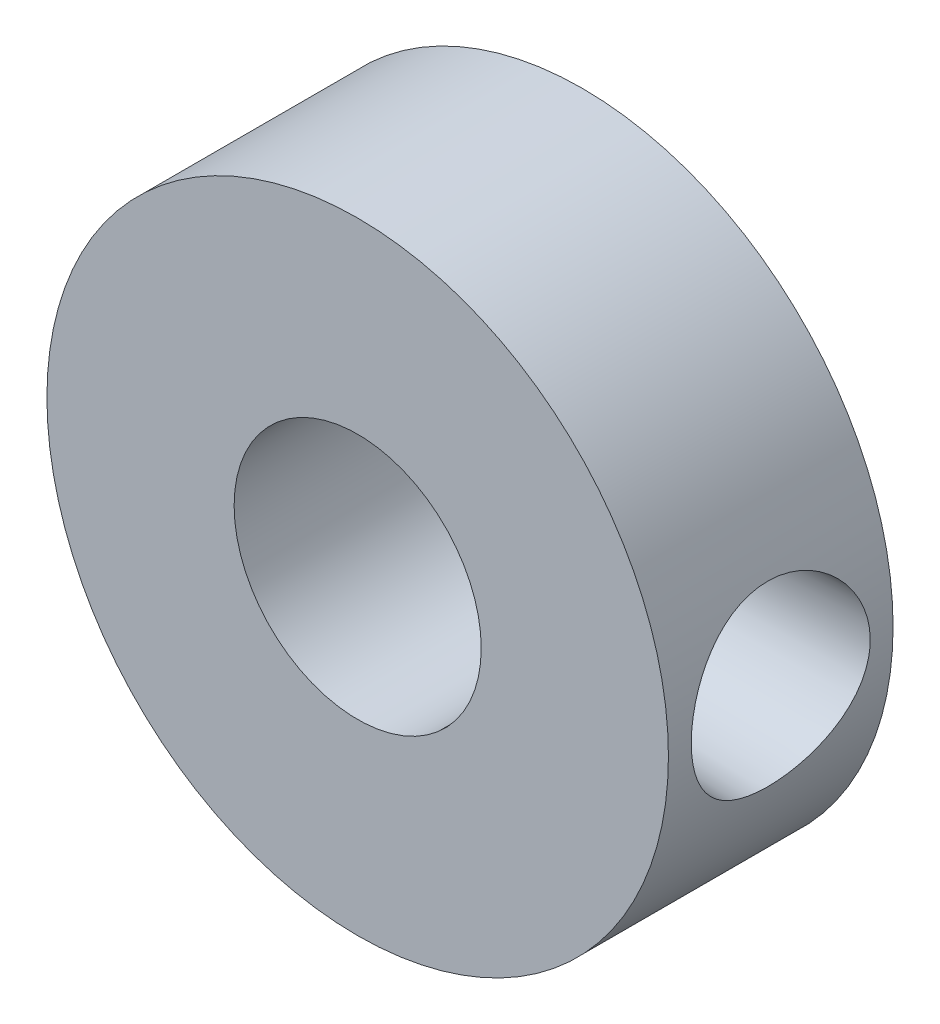
from build123d import *

# Parameters (mm, degrees)
SKETCH1_R           = 10.541
SKETCH1_R_2         = 4.191
BOSS_EXTRUDE1_DEPTH = 7.62
SKETCH2_R           = 2.667
CUT_EXTRUDE1_DEPTH  = 11.541
CUT_EXTRUDE1_TAPER  = -2


with BuildPart() as part:
    # Sketch1 → Boss-Extrude1 (new body)
    with BuildSketch(Plane.XY):
        Circle(SKETCH1_R)
        Circle(SKETCH1_R_2, mode=Mode.SUBTRACT)
    extrude(amount=BOSS_EXTRUDE1_DEPTH)

    # Sketch2 → Cut-Extrude1 (cut, through all)
    with BuildSketch(Plane(origin=(0, 0, 0), x_dir=(0, 0, -1), z_dir=(1, 0, 0))):
        with Locations((-3.81, 0)):
            Circle(SKETCH2_R)
    extrude(amount=CUT_EXTRUDE1_DEPTH, taper=CUT_EXTRUDE1_TAPER, mode=Mode.SUBTRACT)


solid = part.part
